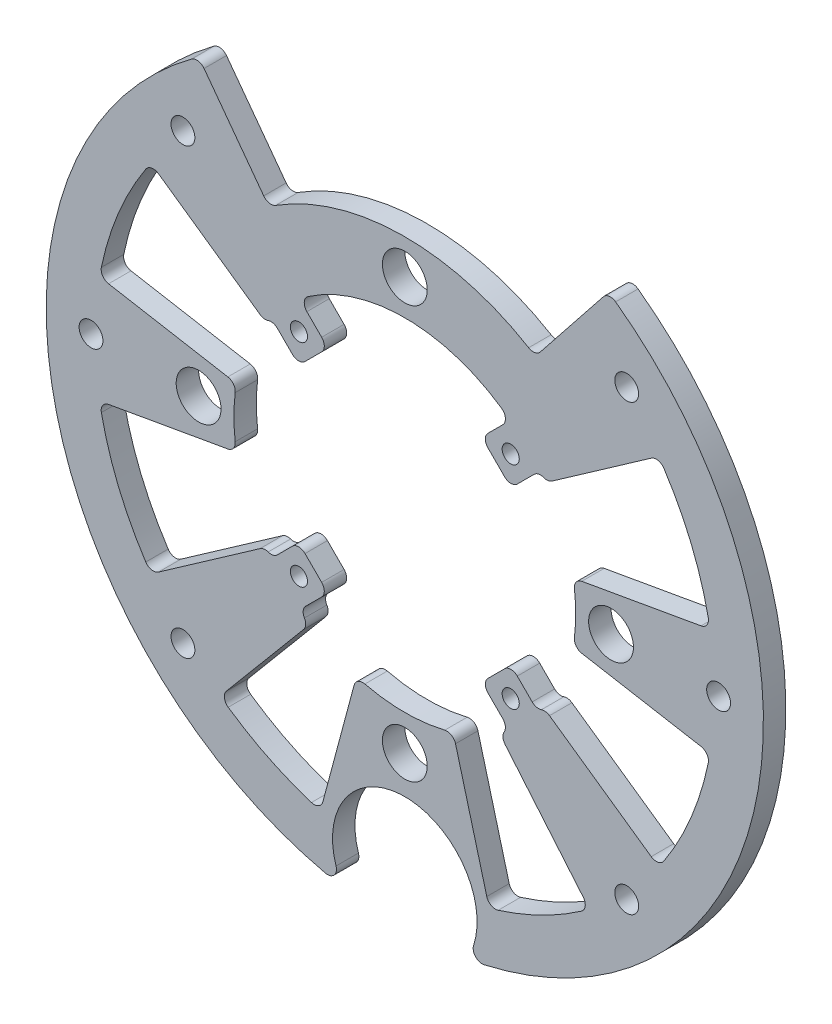
from build123d import *

# Parameters (mm, degrees)
BOSS_EXTRUDE1_DEPTH = 6.35
CUT_EXTRUDE1_DEPTH  = 7.35
SKETCH3_W           = 20.478678418
SKETCH3_H           = 6.35
HOLE1_D             = 4.852996304
HOLE1_DEPTH         = 6.35
HOLE2_D             = 4.852996304
HOLE2_DEPTH         = 6.35
HOLE3_D             = 4.852996304
HOLE4_D             = 4.852996304
HOLE4_DEPTH         = 6.35
HOLE5_D             = 12.7
HOLE5_DEPTH         = 6.35
HOLE6_D             = 12.7
HOLE6_DEPTH         = 6.35
HOLE7_D             = 12.7
HOLE7_DEPTH         = 6.35
HOLE8_D             = 12.7
HOLE8_DEPTH         = 6.35
HOLE9_D             = 6.7564
HOLE9_DEPTH         = 6.35
HOLE9_TIP           = 2.029827343
HOLE10_D            = 6.7564
HOLE10_DEPTH        = 6.35
HOLE10_TIP          = 2.029827343
HOLE11_D            = 6.7564
HOLE11_DEPTH        = 6.35
HOLE11_TIP          = 2.029827343
HOLE12_D            = 6.7564
HOLE12_DEPTH        = 6.35
HOLE12_TIP          = 2.029827343
HOLE13_D            = 6.7564
HOLE13_DEPTH        = 6.35
HOLE13_TIP          = 2.029827343
HOLE14_D            = 6.7564
HOLE14_DEPTH        = 6.35
HOLE14_TIP          = 2.029827343
FILLET1_R           = 2.54
FILLET2_R           = 2.54
FILLET3_R           = 2.54
FILLET4_R           = 2.54
FILLET5_R           = 2.54
FILLET6_R           = 2.54
FILLET7_R           = 2.54
FILLET8_R           = 2.54
FILLET9_R           = 2.54
FILLET10_R          = 2.54
FILLET11_R          = 2.54
FILLET12_R          = 2.54
FILLET13_R          = 2.54
FILLET14_R          = 2.54
FILLET15_R          = 2.54
FILLET16_R          = 2.54
FILLET17_R          = 2.54
FILLET18_R          = 2.54
FILLET19_R          = 2.54
FILLET20_R          = 2.54
FILLET21_R          = 2.54
FILLET22_R          = 2.54
FILLET23_R          = 2.54
FILLET24_R          = 2.54
FILLET25_R          = 2.54
FILLET26_R          = 2.54
FILLET27_R          = 2.54
FILLET28_R          = 2.54
FILLET29_R          = 2.54
FILLET30_R          = 2.54
FILLET31_R          = 2.54
FILLET32_R          = 2.54


with BuildPart() as part:
    # Sketch1 → Boss-Extrude1 (new body)
    with BuildSketch(Plane.XY.offset(6.35)):
        with BuildLine():
            Line((57.744565526, 83.595006742), (36.978423652, 57.45466439))
            ThreePointArc((36.978423652, 57.45466439), (-0.939792187, 68.319536493), (-38.544806548, 56.41577939))
            Line((-38.544806548, 56.41577939), (-58.363526169, 83.1640476))
            ThreePointArc((-58.363526169, 83.1640476), (-99.684749538, -19.63442664), (-22.466842036, -99.084817247))
            ThreePointArc((-22.466842036, -99.084817247), (-20.030710141, -98.321755318), (-19.488041153, -95.827258878))
            ThreePointArc((-19.488041153, -95.827258878), (0, -110.013678418), (19.488041153, -95.827258878))
            ThreePointArc((19.488041153, -95.827258878), (20.030710141, -98.321755318), (22.466842036, -99.084817247))
            ThreePointArc((22.466842036, -99.084817247), (99.756939603, -19.264293422), (57.744565526, 83.595006742))
        make_face()
    extrude(amount=-BOSS_EXTRUDE1_DEPTH)

    # Sketch2 → Cut-Extrude1 (cut, through all)
    with BuildSketch(Plane(origin=(0, 0, 0), x_dir=(-1, 0, 0), z_dir=(0, 0, -1))):
        with BuildLine():
            Line((86.468023222, -15.246645463), (47.700026827, -8.41080171))
            ThreePointArc((47.700026827, -8.41080171), (48.435876627, 0), (47.700026827, 8.41080171))
            Line((47.700026827, 8.41080171), (86.468023222, 15.246645463))
            ThreePointArc((86.468023222, 15.246645463), (81.118407757, 33.600344651), (71.923131973, 50.361119179))
            Line((71.923131973, 50.361119179), (40.995879051, 28.705623547))
            ThreePointArc((40.995879051, 28.705623547), (39.891607191, 28.27086429), (38.710357463, 28.385236629))
            ThreePointArc((38.710357463, 28.385236629), (37.311217501, 28.459304906), (36.085668799, 27.780254744))
            Line((36.085668799, 27.780254744), (30.067243726, 21.76182967))
            Line((30.067243726, 21.76182967), (21.76182967, 30.067243726))
            Line((21.76182967, 30.067243726), (29.843941288, 38.149355343))
            ThreePointArc((29.843941288, 38.149355343), (0, 48.435876627), (-29.843941288, 38.149355343))
            Line((-29.843941288, 38.149355343), (-21.76182967, 30.067243726))
            Line((-21.76182967, 30.067243726), (-30.067243726, 21.76182967))
            Line((-30.067243726, 21.76182967), (-36.638972644, 28.333558588))
            ThreePointArc((-36.638972644, 28.333558588), (-37.90501872, 29.021595636), (-39.341632182, 28.910198107))
            ThreePointArc((-39.341632182, 28.910198107), (-40.559726256, 28.762060292), (-41.705124645, 29.202242658))
            Line((-41.705124645, 29.202242658), (-71.923131973, 50.361119179))
            ThreePointArc((-71.923131973, 50.361119179), (-81.118407757, 33.600344651), (-86.468023222, 15.246645463))
            Line((-86.468023222, 15.246645463), (-47.700026827, 8.41080171))
            ThreePointArc((-47.700026827, 8.41080171), (-48.435876627, 0), (-47.700026827, -8.41080171))
            Line((-47.700026827, -8.41080171), (-86.468023222, -15.246645463))
            ThreePointArc((-86.468023222, -15.246645463), (-81.118407757, -33.600344651), (-71.923131973, -50.361119179))
            Line((-71.923131973, -50.361119179), (-40.995879051, -28.705623547))
            ThreePointArc((-40.995879051, -28.705623547), (-39.891607191, -28.27086429), (-38.710357463, -28.385236629))
            ThreePointArc((-38.710357463, -28.385236629), (-37.311217501, -28.459304906), (-36.085668799, -27.780254744))
            Line((-36.085668799, -27.780254744), (-30.067243726, -21.76182967))
            Line((-30.067243726, -21.76182967), (-21.76182967, -30.067243726))
            Line((-21.76182967, -30.067243726), (-27.750710046, -36.056124101))
            ThreePointArc((-27.750710046, -36.056124101), (-28.473755009, -37.526976312), (-28.147944371, -39.133228992))
            ThreePointArc((-28.147944371, -39.133228992), (-27.810346373, -40.629290723), (-28.395477036, -42.046963187))
            Line((-28.395477036, -42.046963187), (-52.295107345, -70.52943347))
            ThreePointArc((-52.295107345, -70.52943347), (-38.731626443, -78.797464115), (-23.900424698, -84.486383146))
            Line((-23.900424698, -84.486383146), (-13.709958303, -46.455044807))
            ThreePointArc((-13.709958303, -46.455044807), (-0.000167626, -48.435876627), (13.709636762, -46.4551397))
            Line((13.709636762, -46.4551397), (23.900424698, -84.486383146))
            ThreePointArc((23.900424698, -84.486383146), (38.731626442, -78.797464115), (52.295107345, -70.52943347))
            Line((52.295107345, -70.52943347), (28.679533789, -42.383415936))
            ThreePointArc((28.679533789, -42.383415936), (28.093666565, -40.95623193), (28.441774828, -39.453263124))
            ThreePointArc((28.441774828, -39.453263124), (28.778507215, -37.840013838), (28.054254996, -36.359669052))
            Line((28.054254996, -36.359669052), (21.76182967, -30.067243726))
            Line((21.76182967, -30.067243726), (30.067243726, -21.76182967))
            Line((30.067243726, -21.76182967), (36.085668799, -27.780254744))
            ThreePointArc((36.085668799, -27.780254744), (37.311217501, -28.459304906), (38.710357463, -28.385236629))
            ThreePointArc((38.710357463, -28.385236629), (39.891607191, -28.27086429), (40.995879051, -28.705623547))
            Line((40.995879051, -28.705623547), (71.923131973, -50.361119179))
            ThreePointArc((71.923131973, -50.361119179), (81.118407757, -33.600344651), (86.468023222, -15.246645463))
        make_face()
    extrude(amount=-CUT_EXTRUDE1_DEPTH, mode=Mode.SUBTRACT)

    # Sketch3 → Cut-Revolve1 (revolve, cut)
    with BuildSketch(Plane.XZ.offset(89.535)):
        with Locations((10.239339209, 3.175)):
            Rectangle(SKETCH3_W, SKETCH3_H)
    revolve(axis=Axis((0, -89.535, 6.35), (0, 0, -1)), mode=Mode.SUBTRACT)

    # Hole1
    with Locations(Plane.XY.offset(6.35)):
        with Locations((29.99994, 29.99994)):
            Hole(HOLE1_D / 2, depth=HOLE1_DEPTH)

    # Hole2
    with Locations(Plane.XY.offset(6.35)):
        with Locations((-29.99994, 29.99994)):
            Hole(HOLE2_D / 2, depth=HOLE2_DEPTH)

    # Hole3 (through all)
    with Locations(Plane.XY.offset(6.35)):
        with Locations((-29.99994, -29.99994)):
            Hole(HOLE3_D / 2)

    # Hole4
    with Locations(Plane.XY.offset(6.35)):
        with Locations((29.99994, -29.99994)):
            Hole(HOLE4_D / 2, depth=HOLE4_DEPTH)

    # Hole5
    with Locations(Plane.XY.offset(6.35)):
        with Locations((0, 58.42)):
            Hole(HOLE5_D / 2, depth=HOLE5_DEPTH)

    # Hole6
    with Locations(Plane.XY.offset(6.35)):
        with Locations((58.42, 0)):
            Hole(HOLE6_D / 2, depth=HOLE6_DEPTH)

    # Hole7
    with Locations(Plane.XY.offset(6.35)):
        with Locations((-58.42, 0)):
            Hole(HOLE7_D / 2, depth=HOLE7_DEPTH)

    # Hole8
    with Locations(Plane.XY.offset(6.35)):
        with Locations((0, -58.42)):
            Hole(HOLE8_D / 2, depth=HOLE8_DEPTH)

    # Hole9
    with Locations(Plane.XY.offset(6.35)):
        with Locations((62.861792847, -62.861792847)):
            Hole(HOLE9_D / 2, depth=HOLE9_DEPTH)
            with Locations((0, 0, -(HOLE9_DEPTH + HOLE9_TIP / 2))):  # 118° drill point
                Cone(0, HOLE9_D / 2, HOLE9_TIP, mode=Mode.SUBTRACT)

    # Hole10
    with Locations(Plane.XY.offset(6.35)):
        with Locations((88.9, 0)):
            Hole(HOLE10_D / 2, depth=HOLE10_DEPTH)
            with Locations((0, 0, -(HOLE10_DEPTH + HOLE10_TIP / 2))):  # 118° drill point
                Cone(0, HOLE10_D / 2, HOLE10_TIP, mode=Mode.SUBTRACT)

    # Hole11
    with Locations(Plane.XY.offset(6.35)):
        with Locations((62.861792847, 62.861792847)):
            Hole(HOLE11_D / 2, depth=HOLE11_DEPTH)
            with Locations((0, 0, -(HOLE11_DEPTH + HOLE11_TIP / 2))):  # 118° drill point
                Cone(0, HOLE11_D / 2, HOLE11_TIP, mode=Mode.SUBTRACT)

    # Hole12
    with Locations(Plane.XY.offset(6.35)):
        with Locations((-62.861792847, 62.861792847)):
            Hole(HOLE12_D / 2, depth=HOLE12_DEPTH)
            with Locations((0, 0, -(HOLE12_DEPTH + HOLE12_TIP / 2))):  # 118° drill point
                Cone(0, HOLE12_D / 2, HOLE12_TIP, mode=Mode.SUBTRACT)

    # Hole13
    with Locations(Plane.XY.offset(6.35)):
        with Locations((-88.9, 0)):
            Hole(HOLE13_D / 2, depth=HOLE13_DEPTH)
            with Locations((0, 0, -(HOLE13_DEPTH + HOLE13_TIP / 2))):  # 118° drill point
                Cone(0, HOLE13_D / 2, HOLE13_TIP, mode=Mode.SUBTRACT)

    # Hole14
    with Locations(Plane.XY.offset(6.35)):
        with Locations((-62.861792847, -62.861792847)):
            Hole(HOLE14_D / 2, depth=HOLE14_DEPTH)
            with Locations((0, 0, -(HOLE14_DEPTH + HOLE14_TIP / 2))):  # 118° drill point
                Cone(0, HOLE14_D / 2, HOLE14_TIP, mode=Mode.SUBTRACT)

    # Fillet1
    fillet1_edges = [part.edges().sort_by_distance(p)[0] for p in [
        (-86.468023222, 15.246645463, 3.175),
    ]]
    fillet(fillet1_edges, radius=FILLET1_R)

    # Fillet2
    fillet2_edges = [part.edges().sort_by_distance(p)[0] for p in [
        (-52.295107345, -70.52943347, 3.175),
    ]]
    fillet(fillet2_edges, radius=FILLET2_R)

    # Fillet3
    fillet3_edges = [part.edges().sort_by_distance(p)[0] for p in [
        (-38.544806548, 56.41577939, 3.175),
    ]]
    fillet(fillet3_edges, radius=FILLET3_R)

    # Fillet4
    fillet4_edges = [part.edges().sort_by_distance(p)[0] for p in [
        (-23.900424698, -84.486383146, 3.175),
    ]]
    fillet(fillet4_edges, radius=FILLET4_R)

    # Fillet5
    fillet5_edges = [part.edges().sort_by_distance(p)[0] for p in [
        (29.843941288, 38.149355343, 3.175),
    ]]
    fillet(fillet5_edges, radius=FILLET5_R)

    # Fillet6
    fillet6_edges = [part.edges().sort_by_distance(p)[0] for p in [
        (71.923131973, -50.361119179, 3.175),
    ]]
    fillet(fillet6_edges, radius=FILLET6_R)

    # Fillet7
    fillet7_edges = [part.edges().sort_by_distance(p)[0] for p in [
        (-71.923131973, -50.361119179, 3.175),
    ]]
    fillet(fillet7_edges, radius=FILLET7_R)

    # Fillet8
    fillet8_edges = [part.edges().sort_by_distance(p)[0] for p in [
        (-13.709636762, -46.4551397, 3.175),
    ]]
    fillet(fillet8_edges, radius=FILLET8_R)

    # Fillet9
    fillet9_edges = [part.edges().sort_by_distance(p)[0] for p in [
        (86.468023222, -15.246645463, 3.175),
    ]]
    fillet(fillet9_edges, radius=FILLET9_R)

    # Fillet10
    fillet10_edges = [part.edges().sort_by_distance(p)[0] for p in [
        (-47.700026827, 8.41080171, 3.175),
    ]]
    fillet(fillet10_edges, radius=FILLET10_R)

    # Fillet11
    fillet11_edges = [part.edges().sort_by_distance(p)[0] for p in [
        (-71.923131973, 50.361119179, 3.175),
    ]]
    fillet(fillet11_edges, radius=FILLET11_R)

    # Fillet12
    fillet12_edges = [part.edges().sort_by_distance(p)[0] for p in [
        (57.744565526, 83.595006742, 3.175),
    ]]
    fillet(fillet12_edges, radius=FILLET12_R)

    # Fillet13
    fillet13_edges = [part.edges().sort_by_distance(p)[0] for p in [
        (52.295107345, -70.52943347, 3.175),
    ]]
    fillet(fillet13_edges, radius=FILLET13_R)

    # Fillet14
    fillet14_edges = [part.edges().sort_by_distance(p)[0] for p in [
        (47.700026827, 8.41080171, 3.175),
    ]]
    fillet(fillet14_edges, radius=FILLET14_R)

    # Fillet15
    fillet15_edges = [part.edges().sort_by_distance(p)[0] for p in [
        (23.900424698, -84.486383146, 3.175),
    ]]
    fillet(fillet15_edges, radius=FILLET15_R)

    # Fillet16
    fillet16_edges = [part.edges().sort_by_distance(p)[0] for p in [
        (-86.468023222, -15.246645463, 3.175),
    ]]
    fillet(fillet16_edges, radius=FILLET16_R)

    # Fillet17
    fillet17_edges = [part.edges().sort_by_distance(p)[0] for p in [
        (13.709958303, -46.455044807, 3.175),
    ]]
    fillet(fillet17_edges, radius=FILLET17_R)

    # Fillet18
    fillet18_edges = [part.edges().sort_by_distance(p)[0] for p in [
        (71.923131973, 50.361119179, 3.175),
    ]]
    fillet(fillet18_edges, radius=FILLET18_R)

    # Fillet19
    fillet19_edges = [part.edges().sort_by_distance(p)[0] for p in [
        (86.468023222, 15.246645463, 3.175),
    ]]
    fillet(fillet19_edges, radius=FILLET19_R)

    # Fillet20
    fillet20_edges = [part.edges().sort_by_distance(p)[0] for p in [
        (47.700026827, -8.41080171, 3.175),
    ]]
    fillet(fillet20_edges, radius=FILLET20_R)

    # Fillet21
    fillet21_edges = [part.edges().sort_by_distance(p)[0] for p in [
        (21.76182967, 30.067243726, 3.175),
    ]]
    fillet(fillet21_edges, radius=FILLET21_R)

    # Fillet22
    fillet22_edges = [part.edges().sort_by_distance(p)[0] for p in [
        (30.067243726, -21.76182967, 3.175),
    ]]
    fillet(fillet22_edges, radius=FILLET22_R)

    # Fillet23
    fillet23_edges = [part.edges().sort_by_distance(p)[0] for p in [
        (21.76182967, -30.067243726, 3.175),
    ]]
    fillet(fillet23_edges, radius=FILLET23_R)

    # Fillet24
    fillet24_edges = [part.edges().sort_by_distance(p)[0] for p in [
        (-21.76182967, 30.067243726, 3.175),
    ]]
    fillet(fillet24_edges, radius=FILLET24_R)

    # Fillet25
    fillet25_edges = [part.edges().sort_by_distance(p)[0] for p in [
        (-47.700026827, -8.41080171, 3.175),
    ]]
    fillet(fillet25_edges, radius=FILLET25_R)

    # Fillet26
    fillet26_edges = [part.edges().sort_by_distance(p)[0] for p in [
        (-21.76182967, -30.067243726, 3.175),
    ]]
    fillet(fillet26_edges, radius=FILLET26_R)

    # Fillet27
    fillet27_edges = [part.edges().sort_by_distance(p)[0] for p in [
        (30.067243726, 21.76182967, 3.175),
    ]]
    fillet(fillet27_edges, radius=FILLET27_R)

    # Fillet28
    fillet28_edges = [part.edges().sort_by_distance(p)[0] for p in [
        (36.978423652, 57.45466439, 3.175),
    ]]
    fillet(fillet28_edges, radius=FILLET28_R)

    # Fillet29
    fillet29_edges = [part.edges().sort_by_distance(p)[0] for p in [
        (-30.067243726, 21.76182967, 3.175),
    ]]
    fillet(fillet29_edges, radius=FILLET29_R)

    # Fillet30
    fillet30_edges = [part.edges().sort_by_distance(p)[0] for p in [
        (-30.067243726, -21.76182967, 3.175),
    ]]
    fillet(fillet30_edges, radius=FILLET30_R)

    # Fillet31
    fillet31_edges = [part.edges().sort_by_distance(p)[0] for p in [
        (-29.843941288, 38.149355343, 3.175),
    ]]
    fillet(fillet31_edges, radius=FILLET31_R)

    # Fillet32
    fillet32_edges = [part.edges().sort_by_distance(p)[0] for p in [
        (-58.363526169, 83.1640476, 3.175),
    ]]
    fillet(fillet32_edges, radius=FILLET32_R)


solid = part.part
